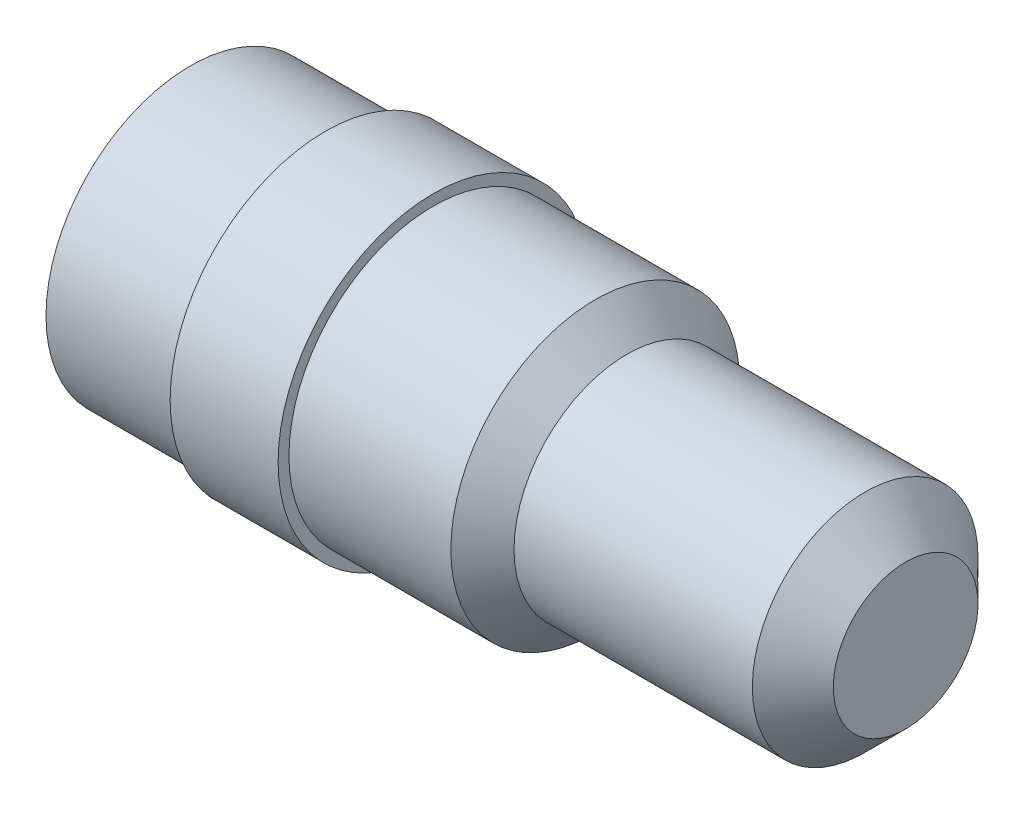
from build123d import *


with BuildPart() as part:
    # Sketch1 → Revolve1 (revolve)
    with BuildSketch(Plane.XY):
        Polygon((0, 0), (26.5, 0), (26.5, 2.68), (25, 4.18), (16.17, 4.18), (15, 5.35), (9, 5.35), (9, 5.75), (5, 5.75), (5, 5.35), (0, 5.35), align=None)
    revolve(axis=Axis((0, 0, 0), (1, 0, 0)))


solid = part.part
